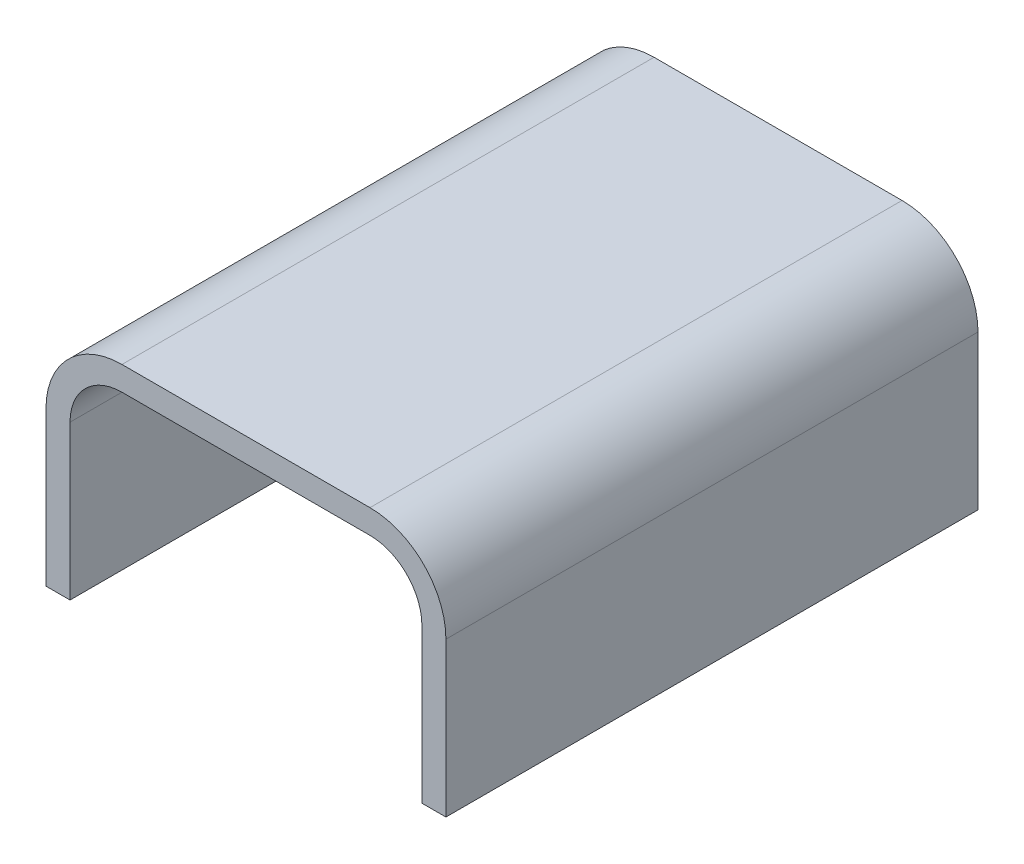
from build123d import *

# Parameters (mm, degrees)
EXTRUDE1_DEPTH = 31


with BuildPart() as part:
    # Sketch2 → Extrude1 (new body)
    with BuildSketch(Plane.XY):
        with BuildLine():
            Line((0, 0), (0, 8.975))
            ThreePointArc((0, 8.975), (0.886001987, 11.113998013), (3.025, 12))
            Line((3.025, 12), (17.475, 12))
            ThreePointArc((17.475, 12), (19.613998013, 11.113998013), (20.5, 8.975))
            Line((20.5, 8.975), (20.5, 0))
            Line((20.5, 0), (21.9, 0))
            Line((21.9, 0), (21.9, 8.975))
            ThreePointArc((21.9, 8.975), (20.603947507, 12.103947507), (17.475, 13.4))
            Line((17.475, 13.4), (3.025, 13.4))
            ThreePointArc((3.025, 13.4), (-0.103947507, 12.103947507), (-1.4, 8.975))
            Line((-1.4, 8.975), (-1.4, 0))
            Line((-1.4, 0), (0, 0))
        make_face()
    extrude(amount=EXTRUDE1_DEPTH)


solid = part.part
